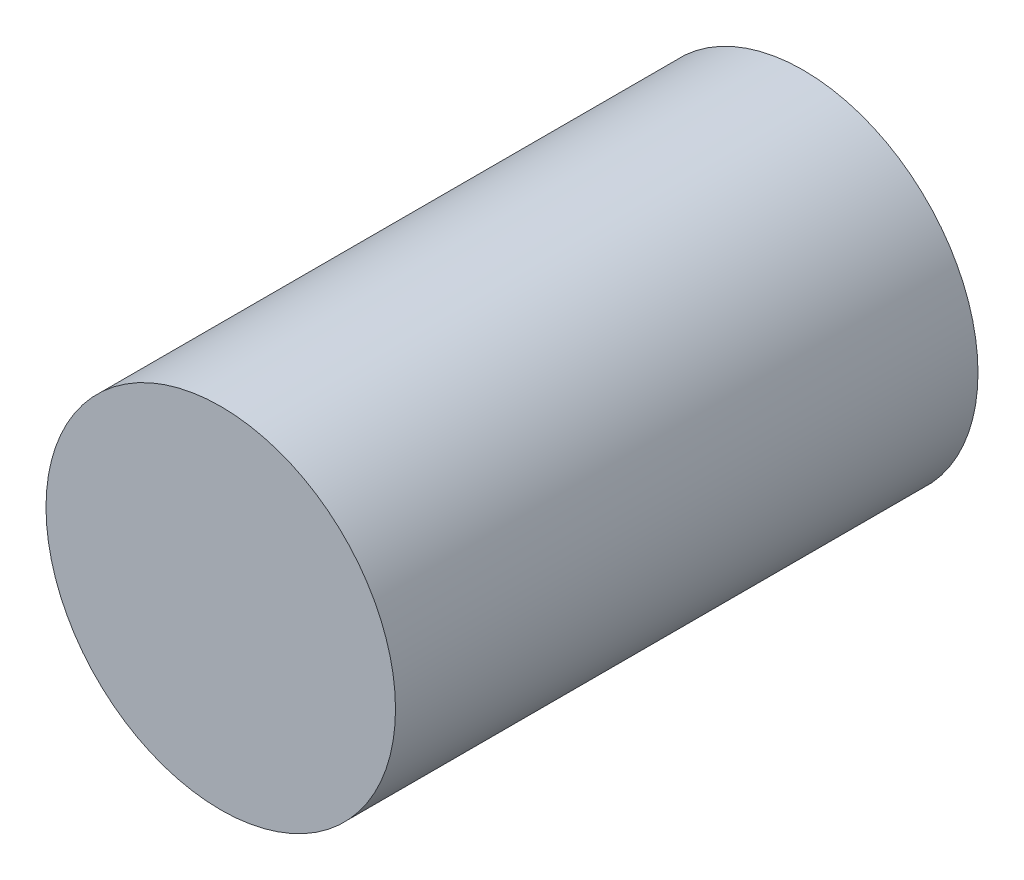
from build123d import *

# Parameters (mm, degrees)
SKETCH2_R           = 1.5
BOSS_EXTRUDE2_DEPTH = 5


with BuildPart() as part:
    # Sketch2 → Boss-Extrude2 (new body)
    with BuildSketch(Plane.XY):
        Circle(SKETCH2_R)
    extrude(amount=BOSS_EXTRUDE2_DEPTH)


solid = part.part
